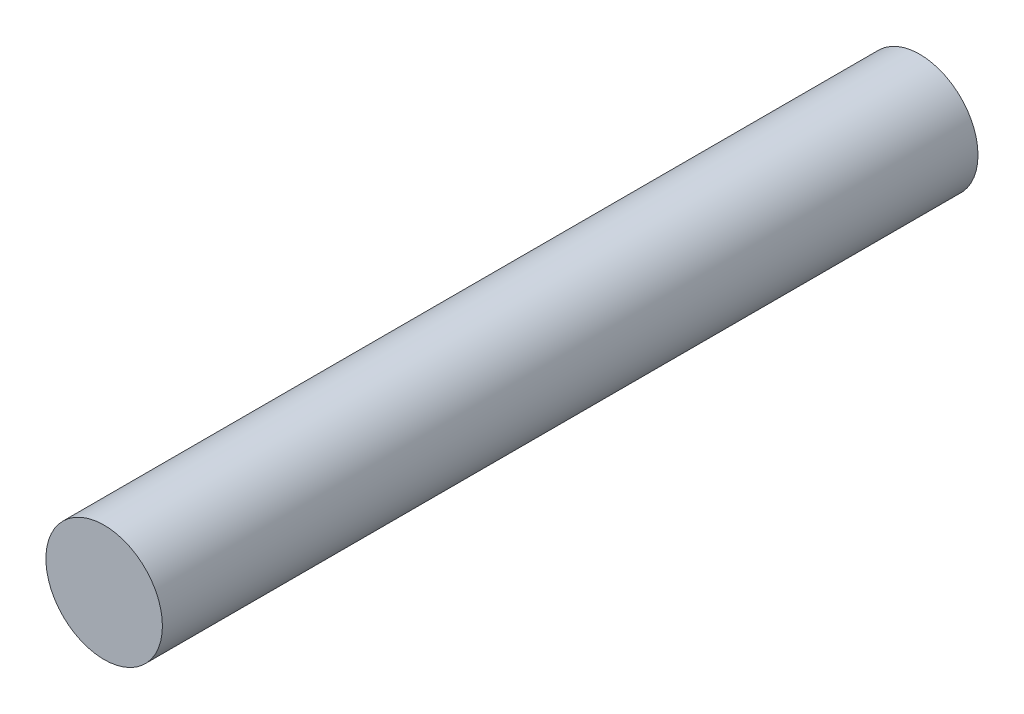
from build123d import *

# Parameters (mm, degrees)
SKETCH1_R           = 1
BOSS_EXTRUDE1_DEPTH = 7


with BuildPart() as part:
    # Sketch1 → Boss-Extrude1 (new body, symmetric)
    with BuildSketch(Plane.XY):
        Circle(SKETCH1_R)
    extrude(amount=BOSS_EXTRUDE1_DEPTH, both=True)


solid = part.part
